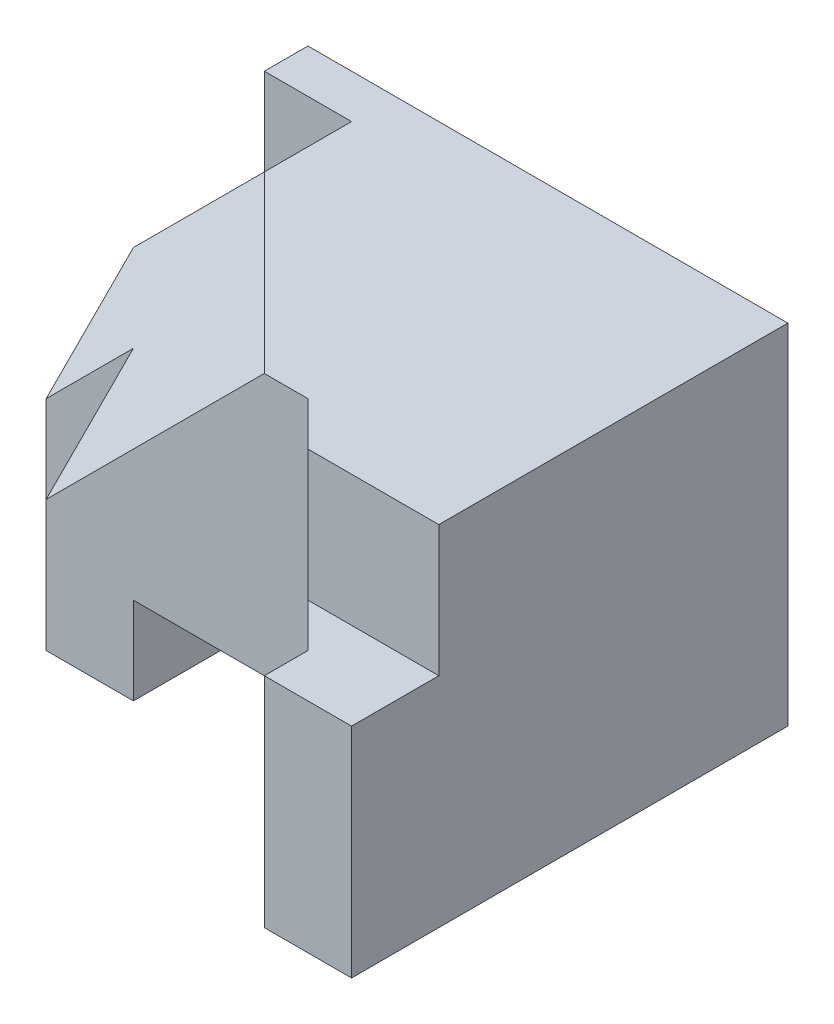
from build123d import *

# Parameters (mm, degrees)
SKETCH1_W                = 120
SKETCH1_H                = 80
BOSS_EXTRUDE1_DEPTH      = 100
SKETCH2_W                = 40
SKETCH2_H                = 20
CUT_EXTRUDE1_DEPTH       = 100
CUT_EXTRUDE2_DEPTH       = 100
SKETCH4_W                = 20
SKETCH4_H                = 50
CUT_EXTRUDE3_DEPTH       = 100
SKETCH5_W                = 60
SKETCH5_H                = 30
CUT_EXTRUDE4_DEPTH       = 100
CUT_EXTRUDE5_DEPTH       = 100
SKETCH7_W                = 30
SKETCH7_H                = 20
CUT_EXTRUDE6_DEPTH       = 30
CUT_EXTRUDE7_DEPTH       = 110
CUT_EXTRUDE8_DEPTH       = 110
CUT_EXTRUDE9_DEPTH       = 110
CUT_EXTRUDE11_DEPTH      = 110
CUT_EXTRUDE12_DEPTH      = 110
CUT_EXTRUDE13_DEPTH      = 110
BOSS_EXTRUDE4_DEPTH      = 50
BOSS_EXTRUDE6_DEPTH      = 40
BOSS_EXTRUDE7_DEPTH      = 40
CUT_EXTRUDE18_DEPTH      = 84
CUT_EXTRUDE18_DEPTH_BACK = 20
CUT_EXTRUDE19_DEPTH      = 20
SKETCH34_W               = 40
SKETCH34_H               = 50
BOSS_EXTRUDE8_DEPTH      = 30
SKETCH35_W               = 20
SKETCH35_H               = 14.142135624
CUT_EXTRUDE20_DEPTH      = 30
SKETCH36_W               = 20
SKETCH36_H               = 30
BOSS_EXTRUDE9_DEPTH      = 30
BOSS_EXTRUDE10_DEPTH     = 30
BOSS_EXTRUDE11_DEPTH     = 30
BOSS_EXTRUDE12_DEPTH     = 30
BOSS_EXTRUDE13_DEPTH     = 30
SKETCH41_W               = 40
SKETCH41_H               = 20
CUT_EXTRUDE21_DEPTH      = 172


with BuildPart() as part:
    # Sketch1 → Boss-Extrude1 (new body)
    with BuildSketch(Plane.XY):
        with Locations((60, 40)):
            Rectangle(SKETCH1_W, SKETCH1_H)
    extrude(amount=-BOSS_EXTRUDE1_DEPTH)

    # Sketch2 → Cut-Extrude1 (cut)
    with BuildSketch(Plane.XY):
        with Locations((60, 10)):
            Rectangle(SKETCH2_W, SKETCH2_H)
    extrude(amount=-CUT_EXTRUDE1_DEPTH, mode=Mode.SUBTRACT)

    # Sketch3 → Cut-Extrude2 (cut)
    with BuildSketch(Plane.XY):
        Polygon((0, 50), (10, 60), (10, 80), (0, 80), align=None)
    extrude(amount=-CUT_EXTRUDE2_DEPTH, mode=Mode.SUBTRACT)

    # Sketch4 → Cut-Extrude3 (cut)
    with BuildSketch(Plane(origin=(0, 0, 0), x_dir=(-1, 0, 0), z_dir=(0, -1, 0))):
        with Locations((-10, 25)):
            Rectangle(SKETCH4_W, SKETCH4_H)
    extrude(amount=-CUT_EXTRUDE3_DEPTH, mode=Mode.SUBTRACT)

    # Sketch5 → Cut-Extrude4 (cut)
    with BuildSketch(Plane(origin=(0, 0, 0), x_dir=(-1, 0, 0), z_dir=(0, -1, 0))):
        with Locations((-50, 15)):
            Rectangle(SKETCH5_W, SKETCH5_H)
    extrude(amount=-CUT_EXTRUDE4_DEPTH, mode=Mode.SUBTRACT)

    # Sketch6 → Cut-Extrude5 (cut)
    with BuildSketch(Plane.XZ):
        Polygon((80, -30), (100, -10), (100, 0), (80, 0), align=None)
    extrude(amount=-CUT_EXTRUDE5_DEPTH, mode=Mode.SUBTRACT)

    # Sketch7 → Cut-Extrude6 (cut)
    with BuildSketch(Plane(origin=(0, 80, 0), x_dir=(1, 0, 0), z_dir=(0, 1, 0))):
        with Locations((105, 10)):
            Rectangle(SKETCH7_W, SKETCH7_H)
    extrude(amount=-CUT_EXTRUDE6_DEPTH, mode=Mode.SUBTRACT)

    # Sketch9 → Cut-Extrude7 (cut)
    with BuildSketch(Plane.XY.offset(-90)):
        Polygon((10, 80), (10, 60), (30, 80), align=None)
    extrude(amount=CUT_EXTRUDE7_DEPTH, mode=Mode.SUBTRACT)

    # Sketch15 → Cut-Extrude8 (cut)
    with BuildSketch(Plane(origin=(6.578947368, -3.947368421, -2.631578947), x_dir=(0.278207442, -0.166924465, 0.945905303), z_dir=(-0.811107106, 0.486664263, 0.324442842))):
        Polygon((-71.221105162, 84.03430672), (-71.221105162, 25.724787771), (-50.077339567, 14.291548762), (-50.077339567, 53.164561394), align=None)
    extrude(amount=CUT_EXTRUDE8_DEPTH, mode=Mode.SUBTRACT)

    # Sketch18 → Cut-Extrude9 (cut)
    with BuildSketch(Plane(origin=(12.371134021, -10.309278351, -12.371134021), x_dir=(-0.468006318, 0.390005265, -0.793010706), z_dir=(0.609207699, -0.507673083, -0.609207699))):
        Polygon((72.670981065, 80.663234358), (22.230300111, 106.270610344), (22.230300111, 28.168113585), align=None)
    extrude(amount=-CUT_EXTRUDE9_DEPTH, mode=Mode.SUBTRACT)

    # Sketch19 → Cut-Extrude11 (cut)
    with BuildSketch(Plane(origin=(11.193675889, -9.328063241, -7.928853755), x_dir=(0.367189278, -0.305991065, 0.878374352), z_dir=(-0.674785869, 0.562321557, 0.477973324))):
        Polygon((-25.127266295, 106.270610344), (-70.665936585, 106.270610344), (-70.665936585, 23.046638388), (-25.127266295, 28.168113585), align=None)
    extrude(amount=CUT_EXTRUDE11_DEPTH, mode=Mode.SUBTRACT)

    # Sketch20 → Cut-Extrude12 (cut)
    with BuildSketch(Plane(origin=(18.330133634, 24.566158479, -3.023527197), x_dir=(0.803624389, -0.590679852, 0.072699059), z_dir=(0.595136826, 0.797606055, -0.098166899))):
        Polygon((-14.663450209, 46.256870976), (-22.809329684, 65.811114724), (-10.365705355, 46.571670512), align=None)
    extrude(amount=-CUT_EXTRUDE12_DEPTH, mode=Mode.SUBTRACT)

    # Sketch23 → Cut-Extrude13 (cut)
    with BuildSketch(Plane.XY.offset(-70)):
        Polygon((0, 30), (0, 80), (41.666666667, 80), align=None)
    extrude(amount=CUT_EXTRUDE13_DEPTH, mode=Mode.SUBTRACT)

    # Sketch27 → Boss-Extrude4 (add)
    with BuildSketch(Plane.XY.offset(-30)):
        Polygon((20, 20), (70, 80), (20, 30), align=None)
    extrude(amount=-BOSS_EXTRUDE4_DEPTH)

    # Sketch28 → Boss-Extrude6 (add)
    with BuildSketch(Plane(origin=(6.666666667, -6.666666667, -6.666666667), x_dir=(0.816496581, 0.40824829, 0.40824829), z_dir=(-0.577350269, 0.577350269, 0.577350269))):
        Polygon((28.577380332, 106.066017178), (77.567175188, 77.781745931), (16.329931619, 42.426406871), (-8.164965809, 84.852813742), align=None)
    extrude(amount=-BOSS_EXTRUDE6_DEPTH)

    # Sketch29 → Boss-Extrude7 (add)
    with BuildSketch(Plane(origin=(0, 80, 0), x_dir=(1, 0, 0), z_dir=(0, 1, 0))):
        Polygon((30, 70), (41.666666667, 70), (70, 30), align=None)
    extrude(amount=-BOSS_EXTRUDE7_DEPTH)

    # Sketch30 → Cut-Extrude18 (cut, two sides)
    with BuildSketch(Plane.XY.offset(-50)) as cut_extrude18_sk:
        Polygon((0, 0), (0, 30), (20, 50), (20, 0), align=None)
    extrude(amount=CUT_EXTRUDE18_DEPTH, mode=Mode.SUBTRACT)
    extrude(cut_extrude18_sk.sketch, amount=-CUT_EXTRUDE18_DEPTH_BACK, mode=Mode.SUBTRACT)

    # Sketch33 → Cut-Extrude19 (cut)
    with BuildSketch(Plane(origin=(11.193675889, -9.328063241, -7.928853755), x_dir=(0.367189278, -0.305991065, 0.878374352), z_dir=(-0.674785869, 0.562321557, 0.477973324))):
        Polygon((-70.665936585, 37.247092344), (-67.987191274, 37.130695181), (-70.665936585, 23.046638388), align=None)
    extrude(amount=-CUT_EXTRUDE19_DEPTH, mode=Mode.SUBTRACT)

    # Sketch34 → Boss-Extrude8 (add)
    with BuildSketch(Plane(origin=(0, 0, -100), x_dir=(-1, 0, 0), z_dir=(0, 0, -1))):
        with Locations((-20, 25)):
            Rectangle(SKETCH34_W, SKETCH34_H)
    extrude(amount=-BOSS_EXTRUDE8_DEPTH)

    # Sketch35 → Cut-Extrude20 (cut)
    with BuildSketch(Plane(origin=(-15, 15, 0), x_dir=(0, 0, -1), z_dir=(0.707106781, -0.707106781, 0))):
        with Locations((60, 42.426406871)):
            Rectangle(SKETCH35_W, SKETCH35_H)
    extrude(amount=-CUT_EXTRUDE20_DEPTH, mode=Mode.SUBTRACT)

    # Sketch36 → Boss-Extrude9 (add)
    with BuildSketch(Plane.ZY):
        with Locations((-60, 15)):
            Rectangle(SKETCH36_W, SKETCH36_H)
    extrude(amount=-BOSS_EXTRUDE9_DEPTH)

    # Sketch37 → Boss-Extrude10 (add)
    with BuildSketch(Plane.XY.offset(-50)):
        Polygon((0, 30), (20, 50), (20, 30), align=None)
    extrude(amount=-BOSS_EXTRUDE10_DEPTH)

    # Sketch38 → Boss-Extrude11 (add)
    with BuildSketch(Plane(origin=(6.666666667, -6.666666667, -6.666666667), x_dir=(0.816496581, 0.40824829, 0.40824829), z_dir=(-0.577350269, 0.577350269, 0.577350269))):
        Polygon((4.082482905, 91.923881554), (-8.164965809, 56.568542495), (16.329931619, 70.710678119), align=None)
    extrude(amount=-BOSS_EXTRUDE11_DEPTH)

    # Sketch39 → Boss-Extrude12 (add)
    with BuildSketch(Plane(origin=(6.666666667, -6.666666667, -6.666666667), x_dir=(0.816496581, 0.40824829, 0.40824829), z_dir=(-0.577350269, 0.577350269, 0.577350269))):
        Polygon((-8.164965809, 84.852813742), (4.082482905, 91.923881554), (-8.164965809, 56.568542495), align=None)
    extrude(amount=-BOSS_EXTRUDE12_DEPTH)

    # Sketch40 → Boss-Extrude13 (add)
    with BuildSketch(Plane.ZY):
        Polygon((-70, 30), (-70, 50), (-50, 30), align=None)
    extrude(amount=-BOSS_EXTRUDE13_DEPTH)

    # Sketch41 → Cut-Extrude21 (cut)
    with BuildSketch(Plane.XY.offset(-30)):
        with Locations((60, 10)):
            Rectangle(SKETCH41_W, SKETCH41_H)
    extrude(amount=-CUT_EXTRUDE21_DEPTH, mode=Mode.SUBTRACT)


solid = part.part
